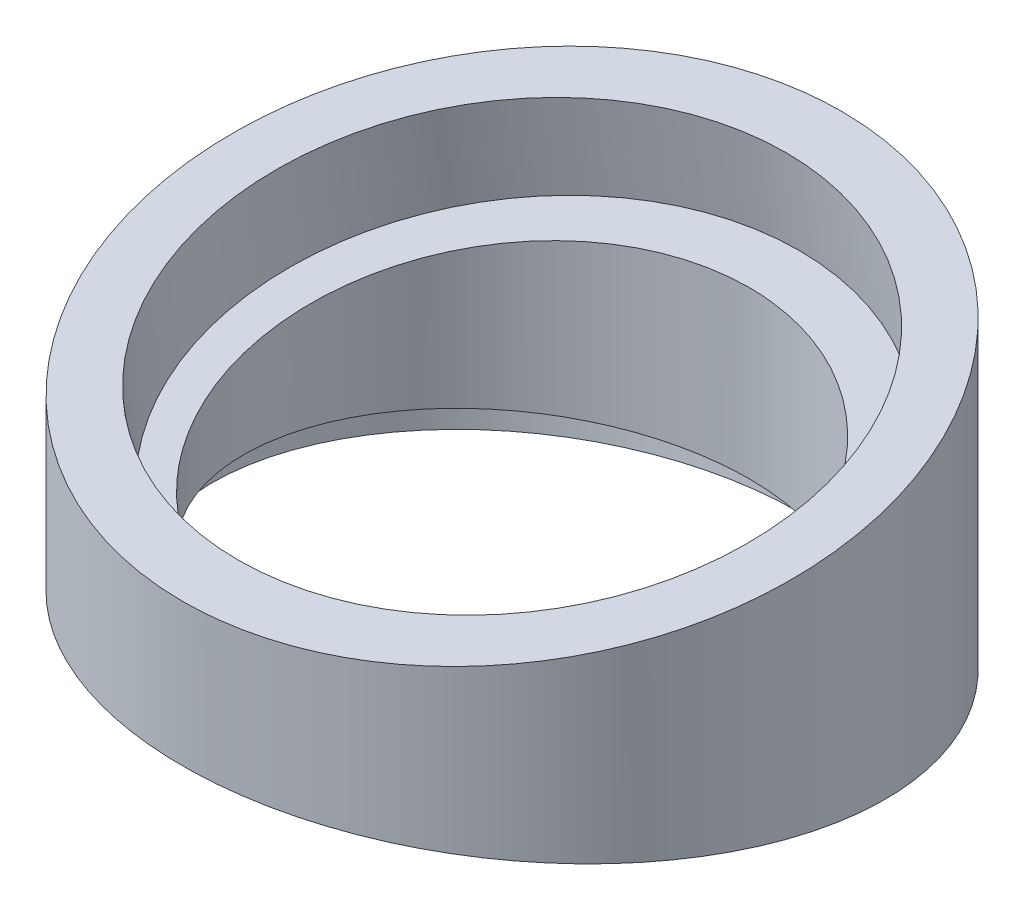
from build123d import *

# Parameters (mm, degrees)
SKETCH_1_R          = 25
EXTRUDE_1_DEPTH     = 30
CUT_EXTRUDE_1_DEPTH = 31.5
SKETCH_7_R          = 21
CUT_EXTRUDE_2_DEPTH = 7
SKETCH_8_R          = 21
CUT_EXTRUDE_3_DEPTH = 3.5
SKETCH_9_R          = 18
CUT_EXTRUDE_4_DEPTH = 107.5


with BuildPart() as part:
    # 草图1 → 凸台-拉伸1 (new body)
    with BuildSketch(Plane(origin=(0, 0, 0), x_dir=(1, 0, 0), z_dir=(0, 1, 0))):
        Circle(SKETCH_1_R)
    extrude(amount=EXTRUDE_1_DEPTH)

    # 草图3 → 切除-拉伸1 (cut, symmetric)
    with BuildSketch(Plane(origin=(0, 0, 0), x_dir=(0, 0, -1), z_dir=(1, 0, 0))):
        Polygon((-25, 18), (25, 25.188898505), (25, 39.510034579), (-25, 39.510034579), align=None)
        Polygon((25, 0), (-25, 7.188898505), (-25, -17.358468242), (25, -17.358468242), align=None)
    extrude(amount=CUT_EXTRUDE_1_DEPTH, both=True, mode=Mode.SUBTRACT)

    # 草图7 → 切除-拉伸2 (cut)
    with BuildSketch(Plane(origin=(0, 21.15708772, 3.041923126), x_dir=(1, 0, 0), z_dir=(0, 0.989821487, 0.142314524))):
        with Locations((0, 3.07320377)):
            Circle(SKETCH_7_R)
    extrude(amount=-CUT_EXTRUDE_2_DEPTH, mode=Mode.SUBTRACT)

    # 草图8 → 切除-拉伸3 (cut)
    with BuildSketch(Plane(origin=(0, 3.521649349, -0.506335595), x_dir=(-1, 0, 0), z_dir=(0, -0.989821487, 0.142314524))):
        with Locations((0, 0.488457665)):
            Circle(SKETCH_8_R)
    extrude(amount=-CUT_EXTRUDE_3_DEPTH, mode=Mode.SUBTRACT)

    # 草图9 → 切除-拉伸4 (cut)
    with BuildSketch(Plane(origin=(0, 0, 0), x_dir=(1, 0, 0), z_dir=(0, 1, 0))):
        Circle(SKETCH_9_R)
    extrude(amount=CUT_EXTRUDE_4_DEPTH, mode=Mode.SUBTRACT)


solid = part.part
